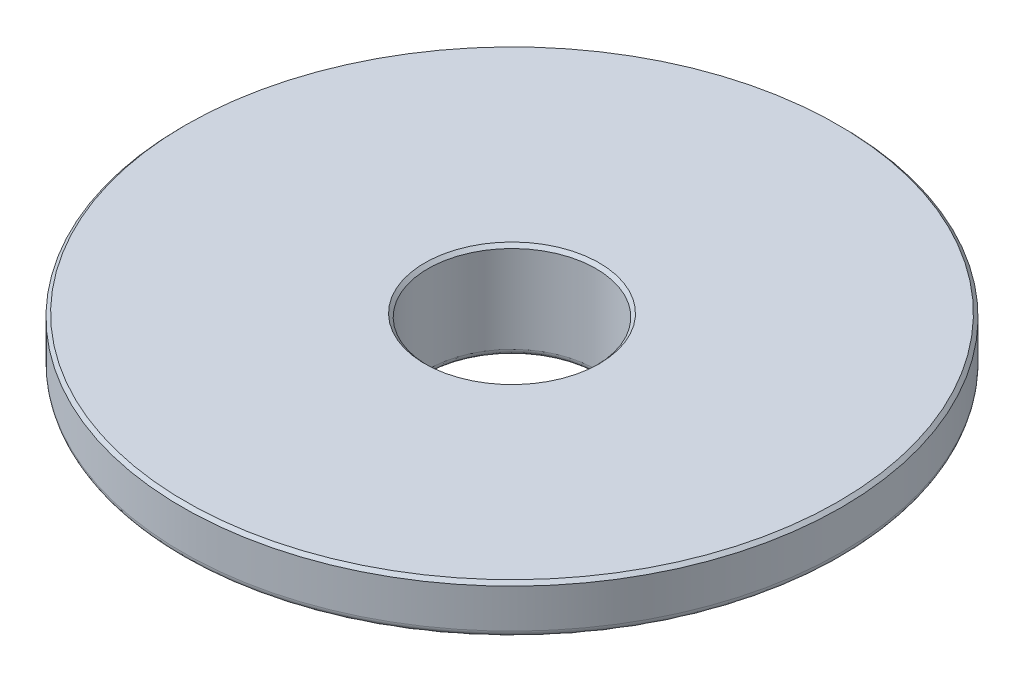
from build123d import *

# Parameters (mm, degrees)
CHAMFER2_SIZE = 0.254
FILLET2_R     = 0.508
FILLET3_R     = 0.127


with BuildPart() as part:
    # Sketch2 → Revolve2 (revolve)
    with BuildSketch(Plane.XY, mode=Mode.PRIVATE) as revolve2_sk:
        with BuildLine():
            Line((25.4, -65.5447), (25.4, -69.155670232))
            ThreePointArc((25.4, -69.155670232), (16.078331209, -71.896828795), (6.477, -73.387432141))
            Line((6.477, -73.387432141), (6.477, -65.5447))
            Line((6.477, -65.5447), (25.4, -65.5447))
        make_face()
    revolve(revolve2_sk.sketch.rotate(Axis((0, -73.6727, 0), (0, -1, 0)), 180), axis=Axis((0, -73.6727, 0), (0, -1, 0)))  # turned: the seam where the file's is

    # Sketch3 → Cut-Revolve1 (revolve, cut)
    with BuildSketch(Plane.XY, mode=Mode.PRIVATE) as cut_revolve1_sk:
        with BuildLine():
            Line((6.477, -73.387432141), (6.477, -73.136107262))
            Line((6.477, -73.136107262), (18.984058463, -70.930775406))
            Line((18.984058463, -70.930775406), (18.984058463, -71.184775406))
            ThreePointArc((18.984058463, -71.184775406), (12.778078834, -72.55609848), (6.477, -73.387432141))
        make_face()
    revolve(cut_revolve1_sk.sketch.rotate(Axis((0, 0, 0), (0, -1, 0)), 90), axis=Axis((0, 0, 0), (0, -1, 0)), mode=Mode.SUBTRACT)  # turned: the seam where the file's is

    # Chamfer2
    chamfer2_edges = [part.edges().sort_by_distance(p)[0] for p in [
        (25.4, -65.5447, 0),
        (6.477, -65.5447, 0),
    ]]
    chamfer(chamfer2_edges, length=CHAMFER2_SIZE)

    # Fillet2
    fillet2_edges = [part.edges().sort_by_distance(p)[0] for p in [
        (4.579930622, -73.136107262, -4.579930622),
        (25.4, -69.155670232, 0),
    ]]
    fillet(fillet2_edges, radius=FILLET2_R)

    # Fillet3
    fillet3_edges = [part.edges().sort_by_distance(p)[0] for p in [
        (13.423756474, -71.184775406, -13.423756474),
    ]]
    fillet(fillet3_edges, radius=FILLET3_R)


solid = part.part
